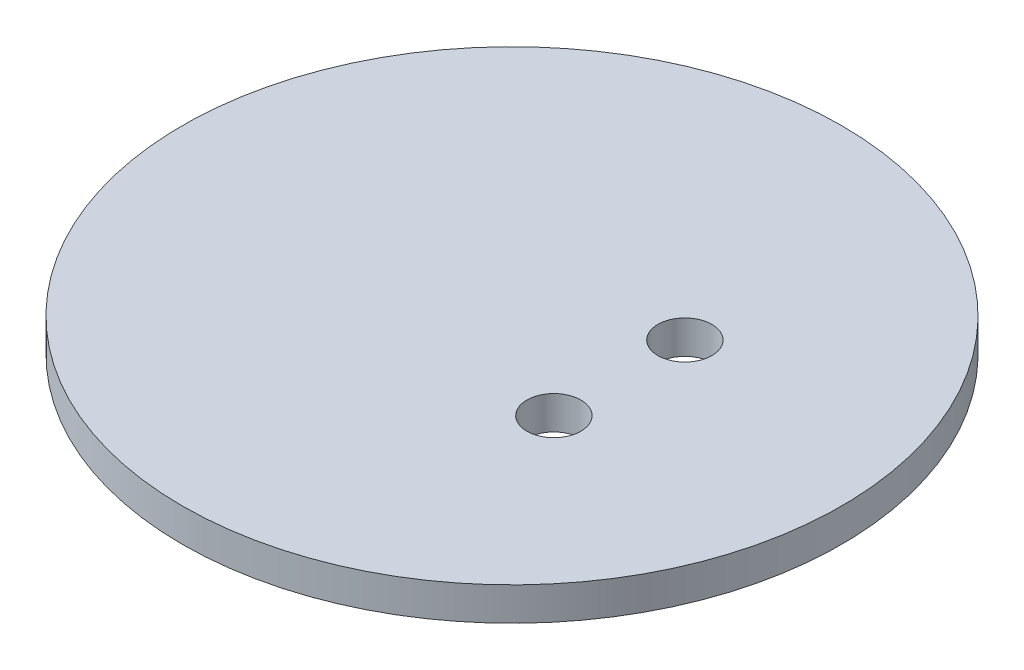
from build123d import *

# Parameters (mm, degrees)
SKETCH1_R           = 7.925
BOSS_EXTRUDE1_DEPTH = 0.8
SKETCH3_R           = 0.65
CUT_EXTRUDE1_DEPTH  = 0.9


with BuildPart() as part:
    # Sketch1 → Boss-Extrude1 (new body)
    with BuildSketch(Plane(origin=(0, 0, 0), x_dir=(1, 0, 0), z_dir=(0, 1, 0))):
        Circle(SKETCH1_R)
    extrude(amount=BOSS_EXTRUDE1_DEPTH)

    # Sketch3 → Cut-Extrude1 (cut)
    with BuildSketch(Plane(origin=(0, 0.8, 0), x_dir=(1, 0, 0), z_dir=(0, 1, 0))):
        with Locations((2.582634314, 1.575)):
            Circle(SKETCH3_R)
        with Locations((2.582634314, -1.575)):
            Circle(SKETCH3_R)
    extrude(amount=-CUT_EXTRUDE1_DEPTH, mode=Mode.SUBTRACT)


solid = part.part
